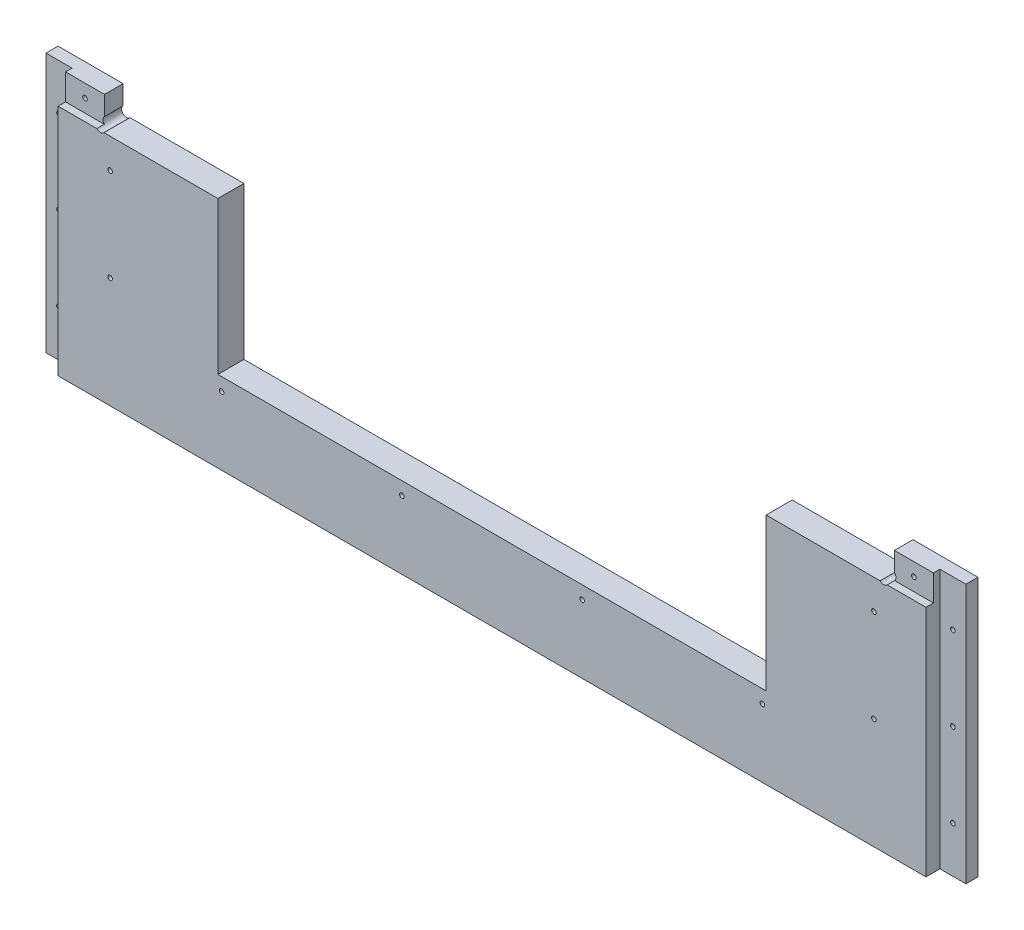
from build123d import *

# Parameters (mm, degrees)
CABCAPOUTLINE_THICKNESS_DEPTH = 17.78
SKETCH3_W                     = 44.45
SKETCH3_H                     = 17.78
CAPBACKLEDGE_DEPTH_DEPTH      = 5.08
CABSIDELEDGECUTS_W            = 17.78
CABSIDELEDGECUTS_H            = 177.363711221
CABSIDELEDGE_DEPTH_DEPTH      = 9.525
SKETCH5_R                     = 1.5875
SKETCH5_R_2                   = 3.302
CUT_EXTRUDE3_DEPTH            = 17.78


with BuildPart() as part:
    # CabCapOutline → CabCapOutline_Thickness (new body)
    with BuildSketch(Plane.XY):
        Polygon((12324.291666666, -6347.976211221), (12324.291666666, -6170.6125), (12279.841666666, -6170.6125), (12279.841666666, -6188.3925), (12197.291666666, -6188.3925), (12197.291666666, -6292.5325), (11822.641666666, -6292.5325), (11822.641666666, -6188.3925), (11740.091666666, -6188.3925), (11740.091666666, -6170.6125), (11695.641666666, -6170.6125), (11695.641666666, -6347.976211221), align=None)
    extrude(amount=-CABCAPOUTLINE_THICKNESS_DEPTH)

    # Sketch3 → CapBackLedge_Depth (cut)
    with BuildSketch(Plane.XY):
        with Locations((11717.866666666, -6179.5025)):
            Rectangle(SKETCH3_W, SKETCH3_H)
        with Locations((12302.066666666, -6179.5025)):
            Rectangle(SKETCH3_W, SKETCH3_H)
    extrude(amount=-CAPBACKLEDGE_DEPTH_DEPTH, mode=Mode.SUBTRACT)

    # CabSideLedgeCuts → CabSideLedge_Depth (cut)
    with BuildSketch(Plane.XY):
        with Locations((11704.531666666, -6259.294355611)):
            Rectangle(CABSIDELEDGECUTS_W, CABSIDELEDGECUTS_H)
        with Locations((12315.401666666, -6259.294355611)):
            Rectangle(CABSIDELEDGECUTS_W, CABSIDELEDGECUTS_H)
    extrude(amount=-CABSIDELEDGE_DEPTH_DEPTH, mode=Mode.SUBTRACT)

    # Sketch5 → Cut-Extrude3 (cut)
    with BuildSketch(Plane.XY):
        with Locations((11704.531666666, -6316.444355611)):
            Circle(SKETCH5_R)
        with Locations((11704.531666666, -6259.294355611)):
            Circle(SKETCH5_R)
        with Locations((11704.531666666, -6202.144355611)):
            Circle(SKETCH5_R)
        with Locations((11726.756666666, -6179.5025)):
            Circle(SKETCH5_R)
        with Locations((11748.981666666, -6208.7125)):
            Circle(SKETCH5_R)
        with Locations((11748.981666666, -6272.2125)):
            Circle(SKETCH5_R)
        with Locations((11825.181666666, -6301.4225)):
            Circle(SKETCH5_R)
        with Locations((11948.371666666, -6301.4225)):
            Circle(SKETCH5_R)
        with Locations((12071.561666666, -6301.4225)):
            Circle(SKETCH5_R)
        with Locations((12194.751666666, -6301.4225)):
            Circle(SKETCH5_R)
        with Locations((12315.401666666, -6316.444355611)):
            Circle(SKETCH5_R)
        with Locations((12315.401666666, -6259.294355611)):
            Circle(SKETCH5_R)
        with Locations((12270.951666666, -6272.2125)):
            Circle(SKETCH5_R)
        with Locations((12270.951666666, -6208.7125)):
            Circle(SKETCH5_R)
        with Locations((12315.401666666, -6202.144355611)):
            Circle(SKETCH5_R)
        with Locations((12293.176666666, -6179.5025)):
            Circle(SKETCH5_R)
        with Locations((11742.336730696, -6186.14743597)):
            Circle(SKETCH5_R_2)
        with Locations((12277.596602636, -6186.14743597)):
            Circle(SKETCH5_R_2)
    extrude(amount=-CUT_EXTRUDE3_DEPTH, mode=Mode.SUBTRACT)


solid = part.part
